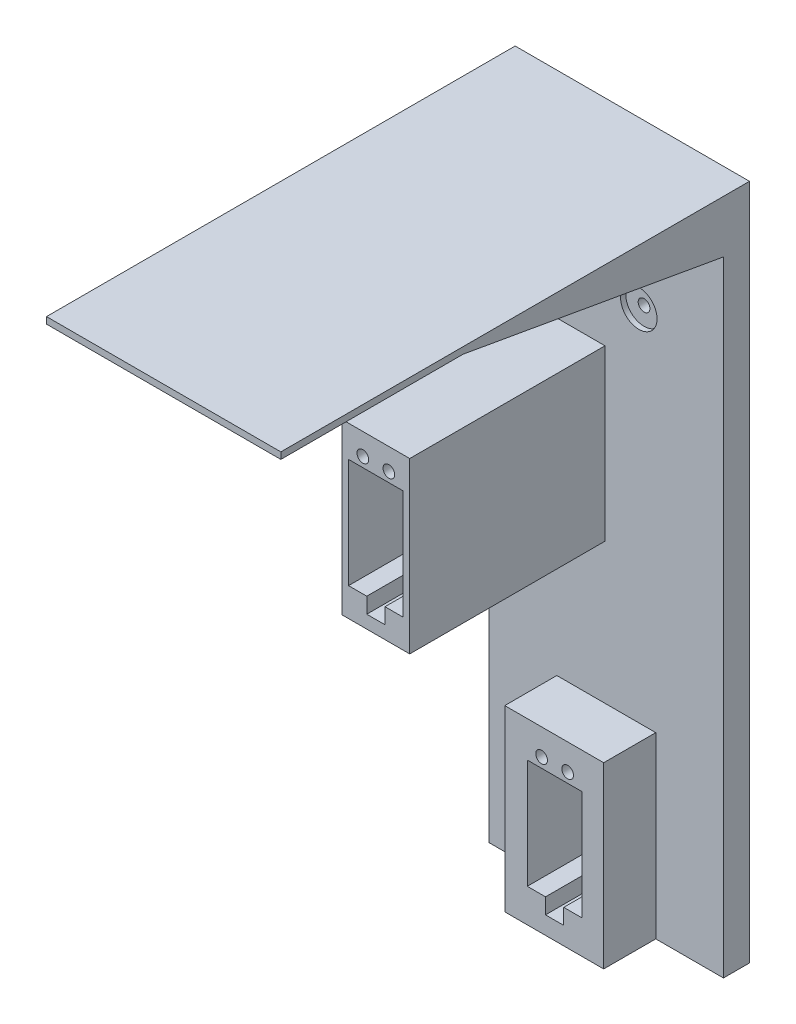
from build123d import *

# Parameters (mm, degrees)
SKETCH1_W           = 150
SKETCH1_H           = 200
BOSS_EXTRUDE1_DEPTH = 30
SKETCH2_W           = 150
SKETCH2_H           = 10
BOSS_EXTRUDE2_DEPTH = 150
SKETCH3_R           = 1.65
SKETCH3_R_2         = 2.25
CUT_EXTRUDE3_DEPTH  = 80
SKETCH6_R           = 5
CUT_EXTRUDE5_DEPTH  = 22
SKETCH7_R           = 1.925
CUT_EXTRUDE6_DEPTH  = 5
FILLET1_R           = 5
SKETCH9_R           = 2.08
CUT_EXTRUDE7_DEPTH  = 30
SKETCH12_W          = 26
SKETCH12_H          = 65
SKETCH12_R          = 2.08
BOSS_EXTRUDE5_DEPTH = 85
SKETCH13_W          = 150
SKETCH13_H          = 60
BOSS_EXTRUDE6_DEPTH = 30
SKETCH15_R          = 2.08
CUT_EXTRUDE8_DEPTH  = 30
SKETCH16_R          = 7
CUT_EXTRUDE9_DEPTH  = 22
SKETCH17_W          = 20
SKETCH17_H          = 260
CUT_EXTRUDE10_DEPTH = 180
SKETCH19_W          = 26
SKETCH19_H          = 65
CUT_EXTRUDE11_DEPTH = 20
SKETCH20_W          = 110
SKETCH20_H          = 12.480627484
CUT_EXTRUDE12_DEPTH = 200
SKETCH21_W          = 10
SKETCH21_H          = 260
CUT_EXTRUDE13_DEPTH = 200
SKETCH22_W          = 21.000744215
SKETCH22_H          = 10
CUT_EXTRUDE14_DEPTH = 80
SKETCH24_W          = 20.877179784
SKETCH24_H          = 9.5
CUT_EXTRUDE15_DEPTH = 25
SKETCH25_R          = 2.25
CUT_EXTRUDE16_DEPTH = 10
SKETCH26_R          = 2.25
CUT_EXTRUDE17_DEPTH = 10
SKETCH27_R          = 2.25
CUT_EXTRUDE18_DEPTH = 10
SKETCH28_R          = 2.25
CUT_EXTRUDE19_DEPTH = 10
SKETCH29_R          = 2.25
CUT_EXTRUDE20_DEPTH = 10
CHAMFER2_SIZE       = 100
CHAMFER2_SIZE2      = 17.632698071
SKETCH33_W          = 40
SKETCH33_H          = 17.63
CUT_EXTRUDE21_DEPTH = 170


with BuildPart() as part:
    # Sketch1 → Boss-Extrude1 (new body)
    with BuildSketch(Plane.XY):
        Rectangle(SKETCH1_W, SKETCH1_H)
    extrude(amount=BOSS_EXTRUDE1_DEPTH)

    # Sketch2 → Boss-Extrude2 (add)
    with BuildSketch(Plane.XY.offset(30)):
        with Locations((0, 95)):
            Rectangle(SKETCH2_W, SKETCH2_H)
    extrude(amount=BOSS_EXTRUDE2_DEPTH)

    # Sketch3 → Cut-Extrude3 (cut)
    with BuildSketch(Plane.XY.offset(30)):
        with Locations((12.5, 46.5)):
            Circle(SKETCH3_R)
        with Locations((-12.5, 46.5)):
            Circle(SKETCH3_R_2)
        with Locations((12.5, 71.5)):
            Circle(SKETCH3_R)
        with Locations((-12.5, 71.5)):
            Circle(SKETCH3_R_2)
    extrude(amount=-CUT_EXTRUDE3_DEPTH, mode=Mode.SUBTRACT)

    # Sketch6 → Cut-Extrude5 (cut)
    with BuildSketch(Plane.XY.offset(30)):
        with Locations((-12.5, 71.5)):
            Circle(SKETCH6_R)
        with Locations((12.5, 71.5)):
            Circle(SKETCH6_R)
        with Locations((-12.5, 46.5)):
            Circle(SKETCH6_R)
        with Locations((12.5, 46.5)):
            Circle(SKETCH6_R)
    extrude(amount=-CUT_EXTRUDE5_DEPTH, mode=Mode.SUBTRACT)

    # Sketch7 → Cut-Extrude6 (cut)
    with BuildSketch(Plane.XY.offset(8)):
        with Locations((-12.5, 71.5)):
            Circle(SKETCH7_R)
        with Locations((12.5, 71.5)):
            Circle(SKETCH7_R)
        with Locations((-12.5, 46.5)):
            Circle(SKETCH7_R)
        with Locations((12.5, 46.5)):
            Circle(SKETCH7_R)
    extrude(amount=-CUT_EXTRUDE6_DEPTH, mode=Mode.SUBTRACT)

    # Fillet1
    fillet1_edges = [part.edges().sort_by_distance(p)[0] for p in [
        (0, 90, 30),
    ]]
    fillet(fillet1_edges, radius=FILLET1_R)

    # Sketch9 → Cut-Extrude7 (cut)
    with BuildSketch(Plane.XY.offset(30)):
        Polygon((-10, -26.5), (-3, -26.5), (-3, 15.5), (-24, 15.5), (-24, -26.5), (-17, -26.5), (-17, -32.5), (-10, -32.5), align=None)
        with Locations((-18.5, 19.25)):
            Circle(SKETCH9_R)
        with Locations((-8.5, 19.25)):
            Circle(SKETCH9_R)
    extrude(amount=-CUT_EXTRUDE7_DEPTH, mode=Mode.SUBTRACT)

    # Sketch12 → Boss-Extrude5 (add)
    with BuildSketch(Plane(origin=(0, 0, 0), x_dir=(-1, 0, 0), z_dir=(0, 0, -1))):
        with Locations((13.5, -4.961410483)):
            Rectangle(SKETCH12_W, SKETCH12_H)
        with Locations((8.5, 19.25)):
            Circle(SKETCH12_R, mode=Mode.SUBTRACT)
        with Locations((18.5, 19.25)):
            Circle(SKETCH12_R, mode=Mode.SUBTRACT)
        Polygon((3, 15.5), (3, -26.5), (10, -26.5), (10, -32.5), (17, -32.5), (17, -26.5), (24, -26.5), (24, 15.5), align=None, mode=Mode.SUBTRACT)
    extrude(amount=-BOSS_EXTRUDE5_DEPTH)

    # Sketch13 → Boss-Extrude6 (add)
    with BuildSketch(Plane(origin=(0, 0, 0), x_dir=(-1, 0, 0), z_dir=(0, 0, -1))):
        with Locations((0, -130)):
            Rectangle(SKETCH13_W, SKETCH13_H)
    extrude(amount=-BOSS_EXTRUDE6_DEPTH)

    # Sketch15 → Cut-Extrude8 (cut)
    with BuildSketch(Plane.XY.offset(30)):
        with Locations((-4.843183012, -101.421536398)):
            Circle(SKETCH15_R)
        with Locations((5.156816988, -101.421536398)):
            Circle(SKETCH15_R)
        Polygon((-10.343183012, -105.171536398), (10.656816988, -105.171536398), (10.656816988, -147.171536398), (3.656816988, -147.171536398), (3.656816988, -153.171536398), (-3.343183012, -153.171536398), (-3.343183012, -147.171536398), (-10.343183012, -147.171536398), align=None)
    extrude(amount=-CUT_EXTRUDE8_DEPTH, mode=Mode.SUBTRACT)

    # Sketch16 → Cut-Extrude9 (cut)
    with BuildSketch(Plane.XY.offset(30)):
        with Locations((-12.5, 71.5)):
            Circle(SKETCH16_R)
        with Locations((12.5, 71.5)):
            Circle(SKETCH16_R)
        with Locations((12.5, 46.5)):
            Circle(SKETCH16_R)
        with Locations((-12.5, 46.5)):
            Circle(SKETCH16_R)
    extrude(amount=-CUT_EXTRUDE9_DEPTH, mode=Mode.SUBTRACT)

    # Sketch17 → Cut-Extrude10 (cut)
    with BuildSketch(Plane(origin=(0, 0, 0), x_dir=(-1, 0, 0), z_dir=(0, 0, -1))):
        with Locations((65, -30)):
            Rectangle(SKETCH17_W, SKETCH17_H)
        with Locations((-65, -30)):
            Rectangle(SKETCH17_W, SKETCH17_H)
    extrude(amount=-CUT_EXTRUDE10_DEPTH, mode=Mode.SUBTRACT)

    # Sketch19 → Cut-Extrude11 (cut)
    with BuildSketch(Plane.XY.offset(30)):
        Polygon((-55, 85), (55, 85), (55, -160), (19, -160), (19, -91.388207499), (-19, -91.388207499), (-19, -160), (-55, -160), align=None)
        with Locations((-13.5, -4.961410483)):
            Rectangle(SKETCH19_W, SKETCH19_H, mode=Mode.SUBTRACT)
    extrude(amount=-CUT_EXTRUDE11_DEPTH, mode=Mode.SUBTRACT)

    # Sketch20 → Cut-Extrude12 (cut)
    with BuildSketch(Plane.XY.offset(10)):
        with Locations((0, 91.240313742)):
            Rectangle(SKETCH20_W, SKETCH20_H)
    extrude(amount=CUT_EXTRUDE12_DEPTH, mode=Mode.SUBTRACT)

    # Sketch21 → Cut-Extrude13 (cut)
    with BuildSketch(Plane(origin=(0, 0, 0), x_dir=(-1, 0, 0), z_dir=(0, 0, -1))):
        with Locations((50, -30)):
            Rectangle(SKETCH21_W, SKETCH21_H)
        with Locations((-50, -30)):
            Rectangle(SKETCH21_W, SKETCH21_H)
    extrude(amount=-CUT_EXTRUDE13_DEPTH, mode=Mode.SUBTRACT)

    # Sketch22 → Cut-Extrude14 (cut)
    with BuildSketch(Plane(origin=(0, 0, 0), x_dir=(-1, 0, 0), z_dir=(0, 0, -1))):
        with Locations((13.500372108, 20.5)):
            Rectangle(SKETCH22_W, SKETCH22_H)
    extrude(amount=-CUT_EXTRUDE14_DEPTH, mode=Mode.SUBTRACT)

    # Sketch24 → Cut-Extrude15 (cut)
    with BuildSketch(Plane(origin=(0, 0, 0), x_dir=(-1, 0, 0), z_dir=(0, 0, -1))):
        with Locations((-0.09540688, -100.421536398)):
            Rectangle(SKETCH24_W, SKETCH24_H)
    extrude(amount=-CUT_EXTRUDE15_DEPTH, mode=Mode.SUBTRACT)

    # Sketch25 → Cut-Extrude16 (cut)
    with BuildSketch(Plane.XY.offset(8)):
        with Locations((12.5, 71.5)):
            Circle(SKETCH25_R)
    extrude(amount=-CUT_EXTRUDE16_DEPTH, mode=Mode.SUBTRACT)

    # Sketch26 → Cut-Extrude17 (cut)
    with BuildSketch(Plane.XY.offset(8)):
        with Locations((12.5, 46.5)):
            Circle(SKETCH26_R)
    extrude(amount=-CUT_EXTRUDE17_DEPTH, mode=Mode.SUBTRACT)

    # Sketch27 → Cut-Extrude18 (cut)
    with BuildSketch(Plane.XY.offset(85)):
        with Locations((-18.5, 19.25)):
            Circle(SKETCH27_R)
    extrude(amount=-CUT_EXTRUDE18_DEPTH, mode=Mode.SUBTRACT)

    # Sketch28 → Cut-Extrude19 (cut)
    with BuildSketch(Plane.XY.offset(85)):
        with Locations((-8.5, 19.25)):
            Circle(SKETCH28_R)
    extrude(amount=-CUT_EXTRUDE19_DEPTH, mode=Mode.SUBTRACT)

    # Sketch29 → Cut-Extrude20 (cut)
    with BuildSketch(Plane.XY.offset(30)):
        with Locations((-4.843183012, -101.421536398)):
            Circle(SKETCH29_R)
        with Locations((5.156816988, -101.421536398)):
            Circle(SKETCH29_R)
    extrude(amount=-CUT_EXTRUDE20_DEPTH, mode=Mode.SUBTRACT)

    # Chamfer2
    chamfer2_edges = [part.edges().sort_by_distance(p)[0] for p in [
        (0, 97.480627484, 10),
    ]]
    chamfer2_side = [part.faces().sort_by_distance(p)[0] for p in [
        (0, 97.480627484, 95),
    ]]
    chamfer(chamfer2_edges, length=CHAMFER2_SIZE, length2=CHAMFER2_SIZE2, reference=chamfer2_side[0])

    # Sketch33 → Cut-Extrude21 (cut)
    with BuildSketch(Plane.XY.offset(10)):
        with Locations((-20, 88.662929413)):
            Rectangle(SKETCH33_W, SKETCH33_H)
        with Locations((20, 88.662929413)):
            Rectangle(SKETCH33_W, SKETCH33_H)
    extrude(amount=CUT_EXTRUDE21_DEPTH, mode=Mode.SUBTRACT)


solid = part.part
